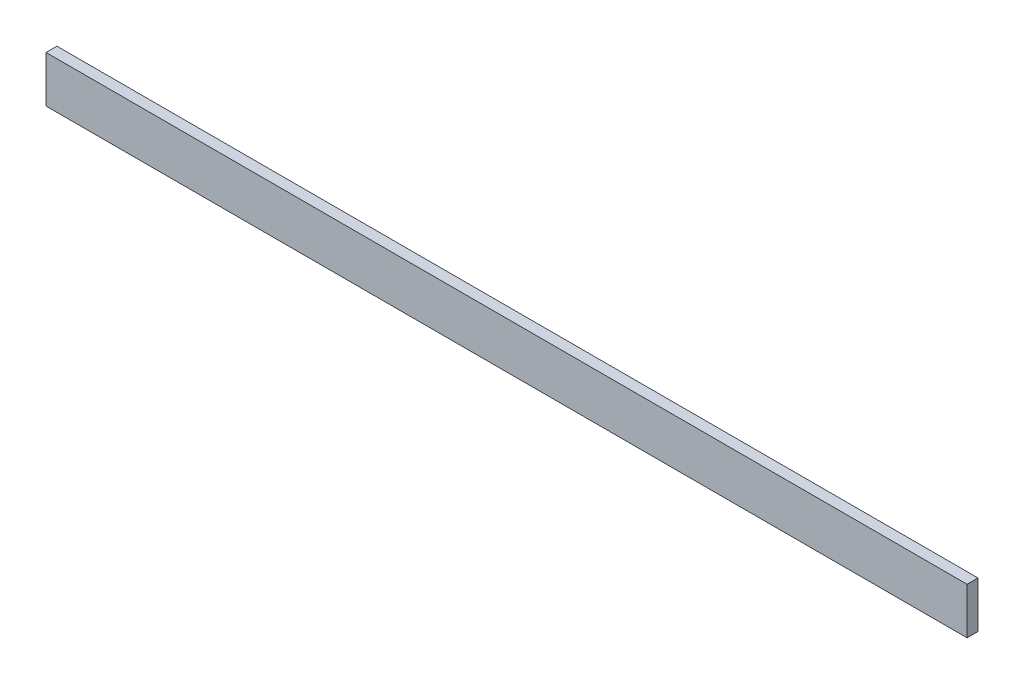
from build123d import *

# Parameters (mm, degrees)
SKETCH1_W           = 1008.126
SKETCH1_H           = 50.8
BOSS_EXTRUDE1_DEPTH = 11.938


with BuildPart() as part:
    # Sketch1 → Boss-Extrude1 (new body)
    with BuildSketch(Plane.XY):
        Rectangle(SKETCH1_W, SKETCH1_H)
    extrude(amount=BOSS_EXTRUDE1_DEPTH)


solid = part.part
